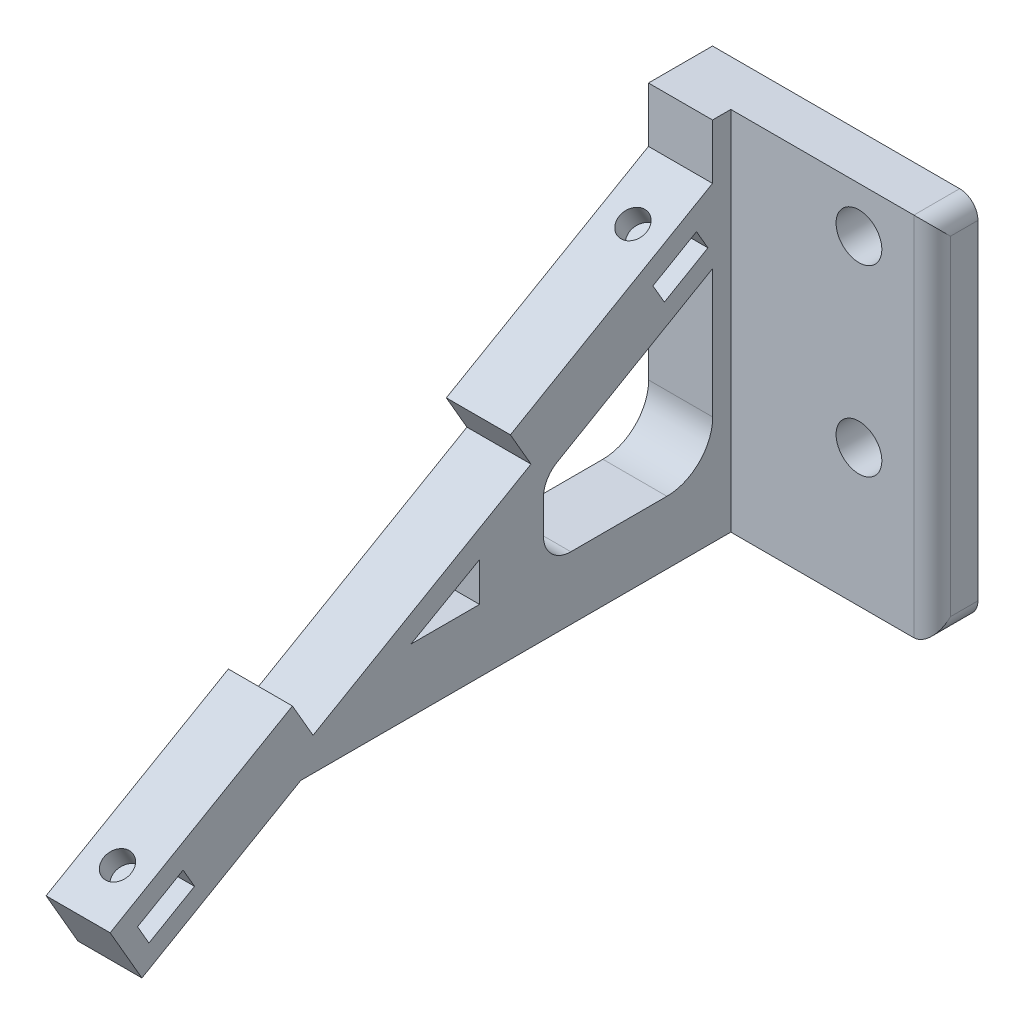
from build123d import *

# Parameters (mm, degrees)
BOSS_EXTRUDE1_DEPTH  = 7000
SKETCH8_W            = 29000
SKETCH8_H            = 40000
SKETCH8_R            = 2500
BOSS_EXTRUDE3_DEPTH  = 5000
FILLET1_R            = 2000
SKETCH9_R            = 1500
CUT_EXTRUDE1_DEPTH   = 7500
FILLET1_OF_MIRROR1_R = 2000
SKETCH10_W           = 30032.748500045
SKETCH10_H           = 50017.623394931
SKETCH10_W_2         = 1774.573147716
SKETCH10_H_2         = 4942.399092914
CUT_EXTRUDE2_DEPTH   = 72818.930687617


with BuildPart() as part:
    # Sketch1 → Boss-Extrude1 (new body)
    with BuildSketch(Plane(origin=(0, 0, 0), x_dir=(0, 0, -1), z_dir=(1, 0, 0))):
        Polygon((-71013.995318758, 7265.898072848), (-90932.579605801, -4234.101927152), (-87458.303118855, -10251.725322083), (-70107.270427744, -234.101927152), (-18114.648918183, -234.101927152), (-18114.648918183, 39765.898072848), (-25114.648918183, 39765.898072848), (-25114.648918183, 33765.898072848), (-47198.296714686, 21015.898072848), (-44948.296714686, 17118.783755818), (-68763.995318758, 3368.783755818), align=None)
        Polygon((-86690.784266902, -7328.011455498), (-87940.784266902, -5162.947946037), (-82961.138195142, -2287.947946037), (-81711.138195142, -4453.011455498), align=None, mode=Mode.SUBTRACT)
        Polygon((-50564.411297588, 6650.031696168), (-58064.411297588, 6650.031696168), (-50564.411297588, 10900.031696168), align=None, mode=Mode.SUBTRACT)
        with BuildLine():
            Line((-42094.842589731, 15873.015861461), (-25094.842589731, 25713.319742243))
            Line((-25094.842589731, 25713.319742243), (-25094.842589731, 11650.031696168))
            ThreePointArc((-25094.842589731, 11650.031696168), (-26559.308683798, 8114.497790235), (-30094.842589731, 6650.031696168))
            Line((-30094.842589731, 6650.031696168), (-40594.842589731, 6650.031696168))
            ThreePointArc((-40594.842589731, 6650.031696168), (-42716.16293329, 7528.711352608), (-43594.842589731, 9650.031696168))
            Line((-43594.842589731, 9650.031696168), (-43594.842589731, 13271.583512645))
            ThreePointArc((-43594.842589731, 13271.583512645), (-43192.9789446, 14773.036997228), (-42094.842589731, 15873.015861461))
        make_face(mode=Mode.SUBTRACT)
        Polygon((-30374.7121835, 25159.479548575), (-31627.131141319, 27323.144669173), (-26867.067876003, 30078.466376377), (-25614.648918183, 27914.801255779), align=None, mode=Mode.SUBTRACT)
    boss_extrude1 = extrude(amount=-BOSS_EXTRUDE1_DEPTH)

    # Sketch8 → Boss-Extrude3 (add)
    with BuildSketch(Plane(origin=(0, 0, 18114.648918183), x_dir=(-1, 0, 0), z_dir=(0, 0, -1))):
        with Locations((14500, 19765.898072848)):
            Rectangle(SKETCH8_W, SKETCH8_H)
        with Locations((21000, 14765.898072848)):
            Circle(SKETCH8_R, mode=Mode.SUBTRACT)
        with Locations((21000, 34765.898072848)):
            Circle(SKETCH8_R, mode=Mode.SUBTRACT)
    boss_extrude3 = extrude(amount=-BOSS_EXTRUDE3_DEPTH)

    # Fillet1
    fillet1_edges = [part.edges().sort_by_distance(p)[0] for p in [
        (-29000, -234.101927152, 20614.648918183),
        (-29000, 19765.898072848, 23114.648918183),
        (-29000, 39765.898072848, 20614.648918183),
    ]]
    fillet(fillet1_edges, radius=FILLET1_R)

    # Sketch9 → Cut-Extrude1 (cut)
    with BuildSketch(Plane(origin=(0, 36199.385539773, 20899.724985887), x_dir=(1, 0, 0), z_dir=(0, 0.866025404, 0.5))):
        with Locations((-3500, -10868.821249998)):
            Circle(SKETCH9_R)
        with Locations((-3500, -75902.875745792)):
            Circle(SKETCH9_R)
    cut_extrude1 = extrude(amount=-CUT_EXTRUDE1_DEPTH, mode=Mode.SUBTRACT)

    # Mirror1: Boss-Extrude1, Boss-Extrude3, Cut-Extrude1 across plane
    add(boss_extrude1.mirror(Plane(origin=(0, 0, 0), x_dir=(0, 0, 1), z_dir=(1, 0, 0))))
    add(boss_extrude3.mirror(Plane(origin=(0, 0, 0), x_dir=(0, 0, 1), z_dir=(1, 0, 0))))
    add(cut_extrude1.mirror(Plane(origin=(0, 0, 0), x_dir=(0, 0, 1), z_dir=(1, 0, 0))), mode=Mode.SUBTRACT)

    # Fillet1 of Mirror1
    fillet1_of_mirror1_edges = [part.edges().sort_by_distance(p)[0] for p in [
        (29000, -234.101927152, 20614.648918183),
        (29000, 19765.898072848, 23114.648918183),
        (29000, 39765.898072848, 20614.648918183),
    ]]
    fillet(fillet1_of_mirror1_edges, radius=FILLET1_OF_MIRROR1_R)

    # Sketch10 → Cut-Extrude2 (cut, through all)
    with BuildSketch(Plane(origin=(0, 0, 18114.648918183), x_dir=(-1, 0, 0), z_dir=(0, 0, -1))):
        with Locations((15016.374250023, 14757.086375382)):
            Rectangle(SKETCH10_W, SKETCH10_H)
        with Locations((35320.938179735, 37487.521083943)):
            Rectangle(SKETCH10_W_2, SKETCH10_H_2)
    extrude(amount=-CUT_EXTRUDE2_DEPTH, mode=Mode.SUBTRACT)


solid = part.part
